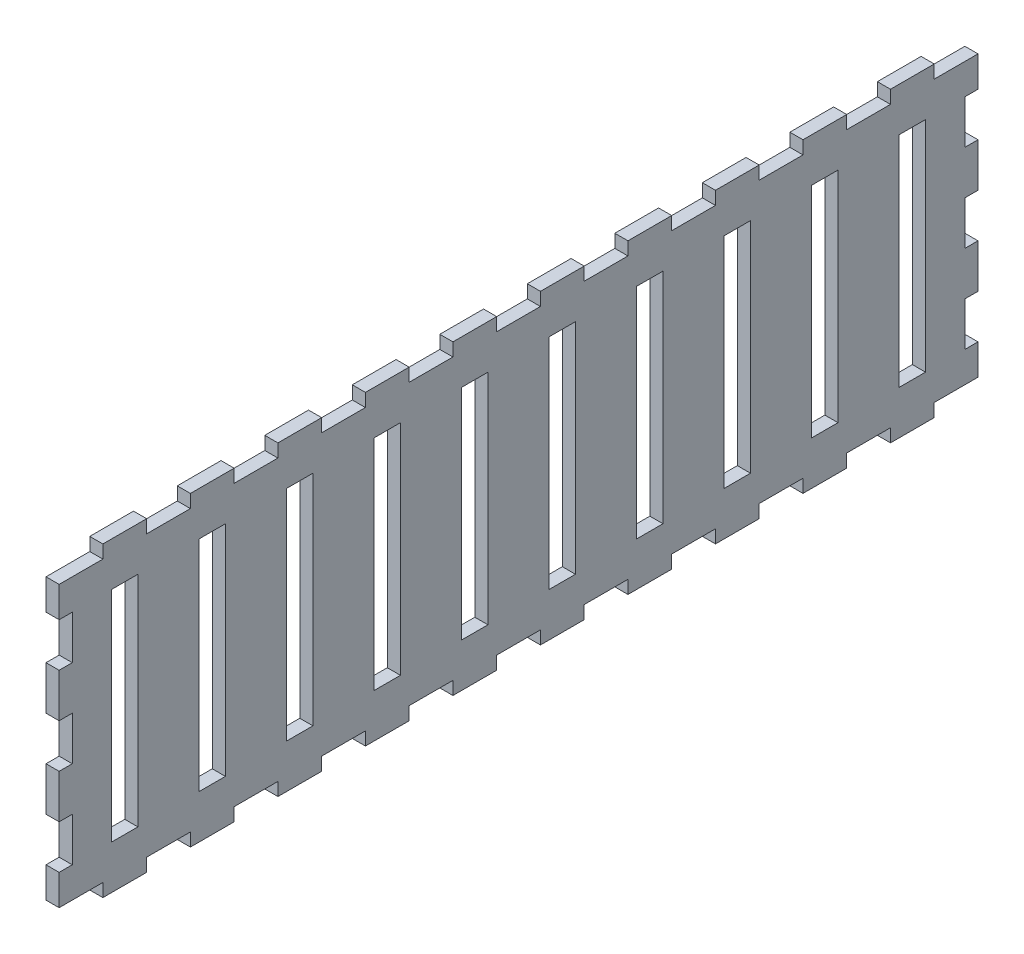
from build123d import *

# Parameters (mm, degrees)
SKETCH1_W                = 210
SKETCH1_H                = 70
BOSS_EXTRUDE1_DEPTH      = 3
SKETCH2_W                = 10
SKETCH2_H                = 3
CUT_EXTRUDE1_DEPTH       = 3
LPATTERN1_COUNT          = 11
LPATTERN1_PITCH          = 20
MIRROR1_COPY_1_SKETCH_W  = 10
MIRROR1_COPY_1_SKETCH_H  = 3
MIRROR1_COPY_1_DEPTH     = 3
MIRROR1_COPY_2_SKETCH_W  = 10
MIRROR1_COPY_2_SKETCH_H  = 3
MIRROR1_COPY_2_DEPTH     = 3
MIRROR1_COPY_3_SKETCH_W  = 10
MIRROR1_COPY_3_SKETCH_H  = 3
MIRROR1_COPY_3_DEPTH     = 3
MIRROR1_COPY_4_SKETCH_W  = 10
MIRROR1_COPY_4_SKETCH_H  = 3
MIRROR1_COPY_4_DEPTH     = 3
MIRROR1_COPY_5_SKETCH_W  = 10
MIRROR1_COPY_5_SKETCH_H  = 3
MIRROR1_COPY_5_DEPTH     = 3
MIRROR1_COPY_6_SKETCH_W  = 10
MIRROR1_COPY_6_SKETCH_H  = 3
MIRROR1_COPY_6_DEPTH     = 3
MIRROR1_COPY_7_SKETCH_W  = 10
MIRROR1_COPY_7_SKETCH_H  = 3
MIRROR1_COPY_7_DEPTH     = 3
MIRROR1_COPY_8_SKETCH_W  = 10
MIRROR1_COPY_8_SKETCH_H  = 3
MIRROR1_COPY_8_DEPTH     = 3
MIRROR1_COPY_9_SKETCH_W  = 10
MIRROR1_COPY_9_SKETCH_H  = 3
MIRROR1_COPY_9_DEPTH     = 3
MIRROR1_COPY_10_SKETCH_W = 10
MIRROR1_COPY_10_SKETCH_H = 3
MIRROR1_COPY_10_DEPTH    = 3
SKETCH3_W                = 3
SKETCH3_H                = 10
CUT_EXTRUDE2_DEPTH       = 3
LPATTERN2_COUNT          = 3
LPATTERN2_PITCH          = 20
MIRROR2_COPY_1_SKETCH_W  = 3
MIRROR2_COPY_1_SKETCH_H  = 10
MIRROR2_COPY_1_DEPTH     = 3
MIRROR2_COPY_2_SKETCH_W  = 3
MIRROR2_COPY_2_SKETCH_H  = 10
MIRROR2_COPY_2_DEPTH     = 3
SKETCH4_W                = 6
SKETCH4_H                = 50
CUT_EXTRUDE3_DEPTH       = 3
LPATTERN3_COUNT          = 10
LPATTERN3_PITCH          = 20


with BuildPart() as part:
    # Sketch1 → Boss-Extrude1 (new body)
    with BuildSketch(Plane(origin=(0, 0, 0), x_dir=(0, 0, -1), z_dir=(1, 0, 0))):
        Rectangle(SKETCH1_W, SKETCH1_H)
    extrude(amount=BOSS_EXTRUDE1_DEPTH)

    # Sketch2 → Cut-Extrude1 (cut)
    with BuildSketch(Plane(origin=(3, 0, 0), x_dir=(0, 0, -1), z_dir=(1, 0, 0))):
        with Locations((-100, 33.5)):
            Rectangle(SKETCH2_W, SKETCH2_H)
    cut_extrude1 = extrude(amount=-CUT_EXTRUDE1_DEPTH, mode=Mode.SUBTRACT)

    # LPattern1: Cut-Extrude1 ×11
    with Locations(*[(0, 0, -i * LPATTERN1_PITCH) for i in range(1, LPATTERN1_COUNT)]):
        add(cut_extrude1, mode=Mode.SUBTRACT)

    # Mirror1: Cut-Extrude1 across plane
    add(cut_extrude1.mirror(Plane.ZX), mode=Mode.SUBTRACT)

    # Mirror1 copy 1 sketch → Mirror1 copy 1 (cut)
    with BuildSketch(Plane(origin=(3, 0, -20), x_dir=(0, 0, -1), z_dir=(1, 0, 0))):
        with Locations((-100, -33.5)):
            Rectangle(MIRROR1_COPY_1_SKETCH_W, MIRROR1_COPY_1_SKETCH_H)
    extrude(amount=-MIRROR1_COPY_1_DEPTH, mode=Mode.SUBTRACT)

    # Mirror1 copy 2 sketch → Mirror1 copy 2 (cut)
    with BuildSketch(Plane(origin=(3, 0, -40), x_dir=(0, 0, -1), z_dir=(1, 0, 0))):
        with Locations((-100, -33.5)):
            Rectangle(MIRROR1_COPY_2_SKETCH_W, MIRROR1_COPY_2_SKETCH_H)
    extrude(amount=-MIRROR1_COPY_2_DEPTH, mode=Mode.SUBTRACT)

    # Mirror1 copy 3 sketch → Mirror1 copy 3 (cut)
    with BuildSketch(Plane(origin=(3, 0, -60), x_dir=(0, 0, -1), z_dir=(1, 0, 0))):
        with Locations((-100, -33.5)):
            Rectangle(MIRROR1_COPY_3_SKETCH_W, MIRROR1_COPY_3_SKETCH_H)
    extrude(amount=-MIRROR1_COPY_3_DEPTH, mode=Mode.SUBTRACT)

    # Mirror1 copy 4 sketch → Mirror1 copy 4 (cut)
    with BuildSketch(Plane(origin=(3, 0, -80), x_dir=(0, 0, -1), z_dir=(1, 0, 0))):
        with Locations((-100, -33.5)):
            Rectangle(MIRROR1_COPY_4_SKETCH_W, MIRROR1_COPY_4_SKETCH_H)
    extrude(amount=-MIRROR1_COPY_4_DEPTH, mode=Mode.SUBTRACT)

    # Mirror1 copy 5 sketch → Mirror1 copy 5 (cut)
    with BuildSketch(Plane(origin=(3, 0, -100), x_dir=(0, 0, -1), z_dir=(1, 0, 0))):
        with Locations((-100, -33.5)):
            Rectangle(MIRROR1_COPY_5_SKETCH_W, MIRROR1_COPY_5_SKETCH_H)
    extrude(amount=-MIRROR1_COPY_5_DEPTH, mode=Mode.SUBTRACT)

    # Mirror1 copy 6 sketch → Mirror1 copy 6 (cut)
    with BuildSketch(Plane(origin=(3, 0, -120), x_dir=(0, 0, -1), z_dir=(1, 0, 0))):
        with Locations((-100, -33.5)):
            Rectangle(MIRROR1_COPY_6_SKETCH_W, MIRROR1_COPY_6_SKETCH_H)
    extrude(amount=-MIRROR1_COPY_6_DEPTH, mode=Mode.SUBTRACT)

    # Mirror1 copy 7 sketch → Mirror1 copy 7 (cut)
    with BuildSketch(Plane(origin=(3, 0, -140), x_dir=(0, 0, -1), z_dir=(1, 0, 0))):
        with Locations((-100, -33.5)):
            Rectangle(MIRROR1_COPY_7_SKETCH_W, MIRROR1_COPY_7_SKETCH_H)
    extrude(amount=-MIRROR1_COPY_7_DEPTH, mode=Mode.SUBTRACT)

    # Mirror1 copy 8 sketch → Mirror1 copy 8 (cut)
    with BuildSketch(Plane(origin=(3, 0, -160), x_dir=(0, 0, -1), z_dir=(1, 0, 0))):
        with Locations((-100, -33.5)):
            Rectangle(MIRROR1_COPY_8_SKETCH_W, MIRROR1_COPY_8_SKETCH_H)
    extrude(amount=-MIRROR1_COPY_8_DEPTH, mode=Mode.SUBTRACT)

    # Mirror1 copy 9 sketch → Mirror1 copy 9 (cut)
    with BuildSketch(Plane(origin=(3, 0, -180), x_dir=(0, 0, -1), z_dir=(1, 0, 0))):
        with Locations((-100, -33.5)):
            Rectangle(MIRROR1_COPY_9_SKETCH_W, MIRROR1_COPY_9_SKETCH_H)
    extrude(amount=-MIRROR1_COPY_9_DEPTH, mode=Mode.SUBTRACT)

    # Mirror1 copy 10 sketch → Mirror1 copy 10 (cut)
    with BuildSketch(Plane(origin=(3, 0, -200), x_dir=(0, 0, -1), z_dir=(1, 0, 0))):
        with Locations((-100, -33.5)):
            Rectangle(MIRROR1_COPY_10_SKETCH_W, MIRROR1_COPY_10_SKETCH_H)
    extrude(amount=-MIRROR1_COPY_10_DEPTH, mode=Mode.SUBTRACT)

    # Sketch3 → Cut-Extrude2 (cut)
    with BuildSketch(Plane(origin=(3, 0, 0), x_dir=(0, 0, -1), z_dir=(1, 0, 0))):
        with Locations((-103.5, 20)):
            Rectangle(SKETCH3_W, SKETCH3_H)
    cut_extrude2 = extrude(amount=-CUT_EXTRUDE2_DEPTH, mode=Mode.SUBTRACT)

    # LPattern2: Cut-Extrude2 ×3
    with Locations(*[(0, -i * LPATTERN2_PITCH, 0) for i in range(1, LPATTERN2_COUNT)]):
        add(cut_extrude2, mode=Mode.SUBTRACT)

    # Mirror2: Cut-Extrude2 across plane
    add(cut_extrude2.mirror(Plane.XY), mode=Mode.SUBTRACT)

    # Mirror2 copy 1 sketch → Mirror2 copy 1 (cut)
    with BuildSketch(Plane(origin=(3, -20, 0), x_dir=(0, 0, 1), z_dir=(1, 0, 0))):
        with Locations((-103.5, -20)):
            Rectangle(MIRROR2_COPY_1_SKETCH_W, MIRROR2_COPY_1_SKETCH_H)
    extrude(amount=-MIRROR2_COPY_1_DEPTH, mode=Mode.SUBTRACT)

    # Mirror2 copy 2 sketch → Mirror2 copy 2 (cut)
    with BuildSketch(Plane(origin=(3, -40, 0), x_dir=(0, 0, 1), z_dir=(1, 0, 0))):
        with Locations((-103.5, -20)):
            Rectangle(MIRROR2_COPY_2_SKETCH_W, MIRROR2_COPY_2_SKETCH_H)
    extrude(amount=-MIRROR2_COPY_2_DEPTH, mode=Mode.SUBTRACT)

    # Sketch4 → Cut-Extrude3 (cut)
    with BuildSketch(Plane(origin=(3, 0, 0), x_dir=(0, 0, -1), z_dir=(1, 0, 0))):
        with Locations((-90, 0)):
            Rectangle(SKETCH4_W, SKETCH4_H)
    cut_extrude3 = extrude(amount=-CUT_EXTRUDE3_DEPTH, mode=Mode.SUBTRACT)

    # LPattern3: Cut-Extrude3 ×10
    with Locations(*[(0, 0, -i * LPATTERN3_PITCH) for i in range(1, LPATTERN3_COUNT)]):
        add(cut_extrude3, mode=Mode.SUBTRACT)


solid = part.part
